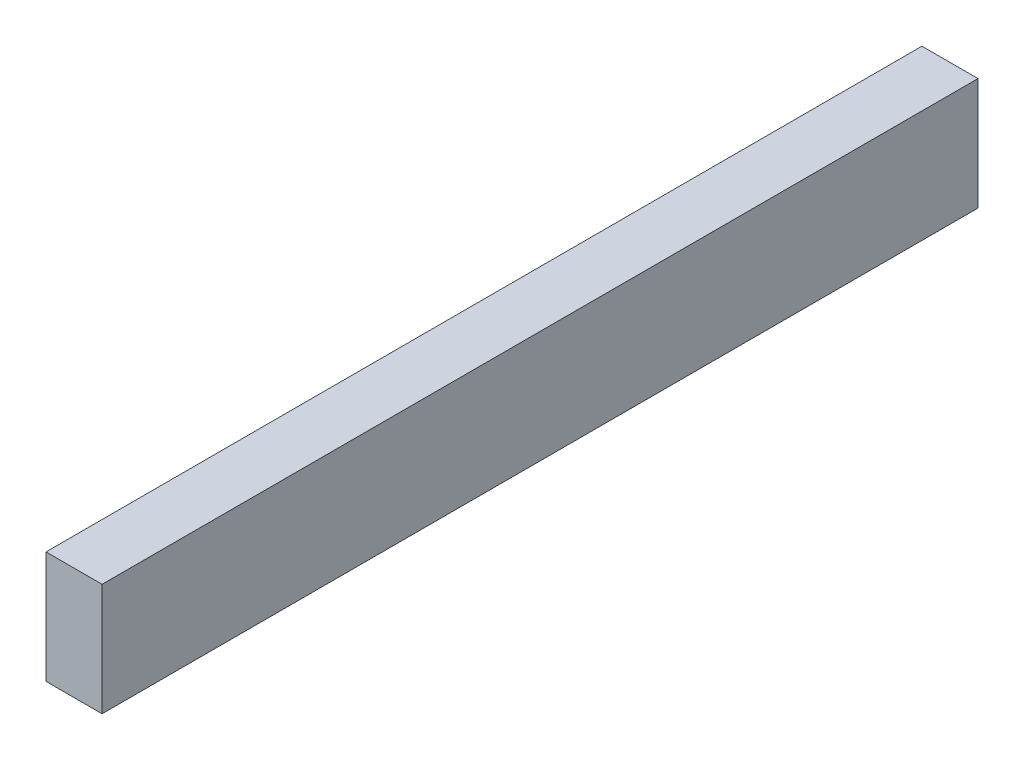
from build123d import *

# Parameters (mm, degrees)
SKETCH1_W           = 297.5356
SKETCH1_H           = 38.1
BOSS_EXTRUDE1_DEPTH = 19.05


with BuildPart() as part:
    # Sketch1 → Boss-Extrude1 (new body)
    with BuildSketch(Plane(origin=(0, 0, 0), x_dir=(0, 0, -1), z_dir=(1, 0, 0))):
        with Locations((29.62190708, -18.471082301)):
            Rectangle(SKETCH1_W, SKETCH1_H)
    extrude(amount=BOSS_EXTRUDE1_DEPTH)


solid = part.part
